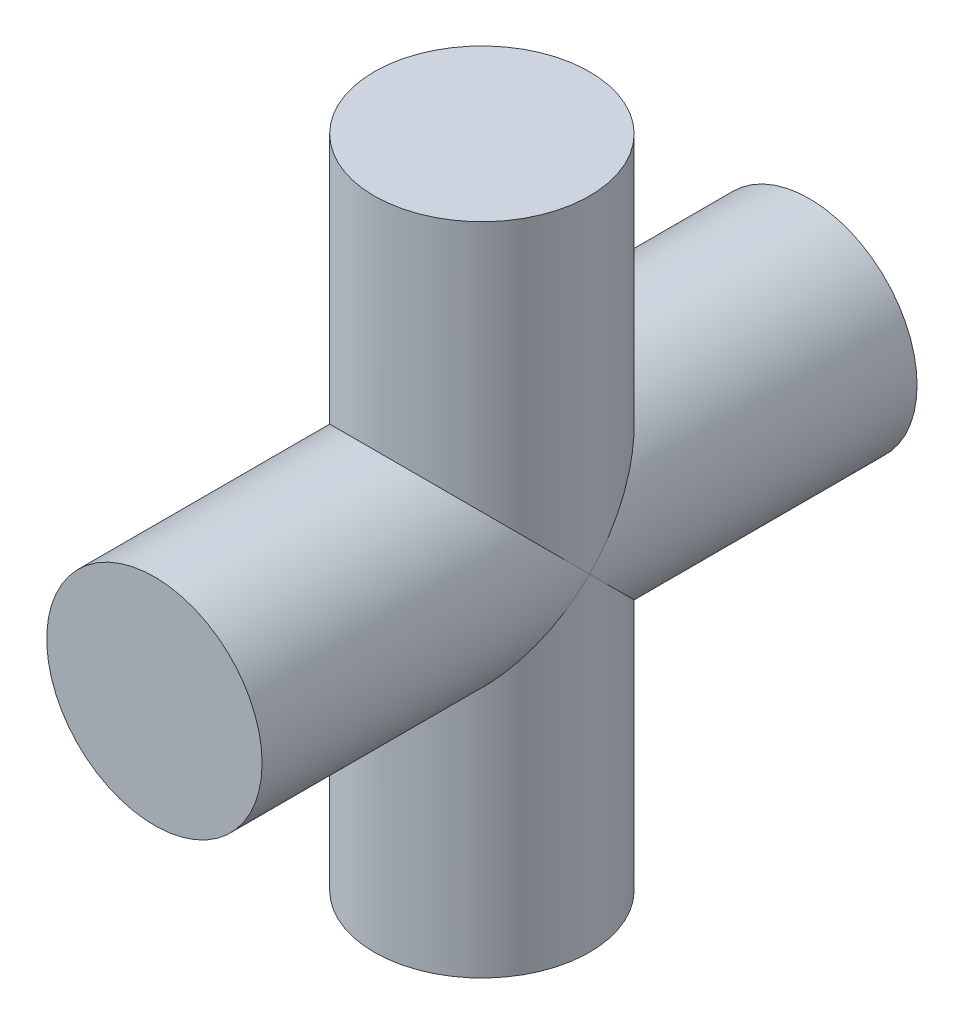
from build123d import *

# Parameters (mm, degrees)
SKETCH1_R                = 12
BOSS_EXTRUDE1_DEPTH      = 73
BOSS_EXTRUDE2_DEPTH      = 36.5
BOSS_EXTRUDE2_DEPTH_BACK = 36.5
SKETCH2_R                = 12


with BuildPart() as part:
    # Sketch1 → Boss-Extrude1 (new body)
    with BuildSketch(Plane(origin=(0, 0, 0), x_dir=(1, 0, 0), z_dir=(0, 1, 0))):
        Circle(SKETCH1_R)
    extrude(amount=BOSS_EXTRUDE1_DEPTH)

    # Sketch2 → Boss-Extrude2 (add, two sides: drawn at the far end of the back side and taken through both)
    with BuildSketch(Plane.XY.offset(-BOSS_EXTRUDE2_DEPTH_BACK)):
        with Locations((0, 36.5)):
            Circle(SKETCH2_R)
    extrude(amount=BOSS_EXTRUDE2_DEPTH + BOSS_EXTRUDE2_DEPTH_BACK)


solid = part.part
